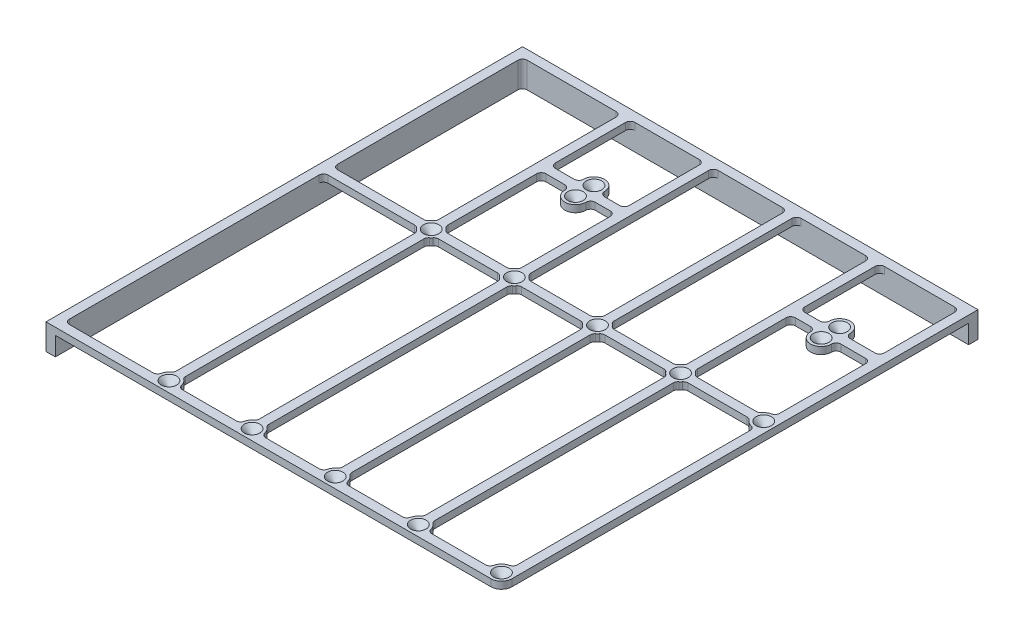
from build123d import *

# Parameters (mm, degrees)
SKETCH1_R           = 0.5
BOSS_EXTRUDE1_DEPTH = 3
BOSS_EXTRUDE2_DEPTH = 8
FILLET1_R           = 2
CHAMFER1_SIZE       = 2.8


with BuildPart() as part:
    # Sketch1 → Boss-Extrude1 (new body)
    with BuildSketch(Plane(origin=(0, 0, 0), x_dir=(1, 0, 0), z_dir=(0, 1, 0))):
        with BuildLine():
            Line((0, -199.5), (-4, -199.5))
            Line((-4, -199.5), (-4, 4))
            Line((-4, 4), (190.5, 4))
            Line((190.5, 4), (190.5, 0))
            Line((190.5, 0), (190.5, -195))
            ThreePointArc((190.5, -195), (189.181980515, -198.181980515), (186, -199.5))
            Line((186, -199.5), (0, -199.5))
        make_face()
        with Locations((44, -195)):
            Circle(SKETCH1_R, mode=Mode.SUBTRACT)
        with Locations((44, -83)):
            Circle(SKETCH1_R, mode=Mode.SUBTRACT)
        with Locations((79.5, -195)):
            Circle(SKETCH1_R, mode=Mode.SUBTRACT)
        with Locations((79.5, -83)):
            Circle(SKETCH1_R, mode=Mode.SUBTRACT)
        with Locations((115, -195)):
            Circle(SKETCH1_R, mode=Mode.SUBTRACT)
        with Locations((115, -83)):
            Circle(SKETCH1_R, mode=Mode.SUBTRACT)
        with Locations((150.5, -195)):
            Circle(SKETCH1_R, mode=Mode.SUBTRACT)
        with Locations((150.5, -83)):
            Circle(SKETCH1_R, mode=Mode.SUBTRACT)
        with Locations((186, -195)):
            Circle(SKETCH1_R, mode=Mode.SUBTRACT)
        with Locations((186, -83)):
            Circle(SKETCH1_R, mode=Mode.SUBTRACT)
        with Locations((62.545, -32.045)):
            Circle(SKETCH1_R, mode=Mode.SUBTRACT)
        with Locations((62.545, -39.955)):
            Circle(SKETCH1_R, mode=Mode.SUBTRACT)
        with Locations((167.455, -32.045)):
            Circle(SKETCH1_R, mode=Mode.SUBTRACT)
        with Locations((167.455, -39.955)):
            Circle(SKETCH1_R, mode=Mode.SUBTRACT)
        with BuildLine():
            Line((186.5, -190.527864045), (186.5, -87.472135955))
            ThreePointArc((186.5, -87.472135955), (183.844754811, -86.950306086), (181.968871126, -85))
            Line((181.968871126, -85), (154.531128874, -85))
            ThreePointArc((154.531128874, -85), (153.681980515, -86.181980515), (152.5, -87.031128874))
            Line((152.5, -87.031128874), (152.5, -190.968871126))
            ThreePointArc((152.5, -190.968871126), (154.450306086, -192.844754811), (154.972135955, -195.5))
            Line((154.972135955, -195.5), (181.527864045, -195.5))
            ThreePointArc((181.527864045, -195.5), (182.818019485, -191.818019485), (186.5, -190.527864045))
        make_face(mode=Mode.SUBTRACT)
        with BuildLine():
            Line((148.5, -190.968871126), (148.5, -87.031128874))
            ThreePointArc((148.5, -87.031128874), (147.318019485, -86.181980515), (146.468871126, -85))
            Line((146.468871126, -85), (119.031128874, -85))
            ThreePointArc((119.031128874, -85), (118.181980515, -86.181980515), (117, -87.031128874))
            Line((117, -87.031128874), (117, -190.968871126))
            ThreePointArc((117, -190.968871126), (118.950306086, -192.844754811), (119.472135955, -195.5))
            Line((119.472135955, -195.5), (146.027864045, -195.5))
            ThreePointArc((146.027864045, -195.5), (146.549693914, -192.844754811), (148.5, -190.968871126))
        make_face(mode=Mode.SUBTRACT)
        with BuildLine():
            Line((83.531128874, -85), (110.968871126, -85))
            ThreePointArc((110.968871126, -85), (111.818019485, -86.181980515), (113, -87.031128874))
            Line((113, -87.031128874), (113, -190.968871126))
            ThreePointArc((113, -190.968871126), (111.049693914, -192.844754811), (110.527864045, -195.5))
            Line((110.527864045, -195.5), (83.972135955, -195.5))
            ThreePointArc((83.972135955, -195.5), (83.450306086, -192.844754811), (81.5, -190.968871126))
            Line((81.5, -190.968871126), (81.5, -87.031128874))
            ThreePointArc((81.5, -87.031128874), (82.681980515, -86.181980515), (83.531128874, -85))
        make_face(mode=Mode.SUBTRACT)
        with BuildLine():
            Line((48.031128874, -85), (75.468871126, -85))
            ThreePointArc((75.468871126, -85), (76.318019485, -86.181980515), (77.5, -87.031128874))
            Line((77.5, -87.031128874), (77.5, -190.968871126))
            ThreePointArc((77.5, -190.968871126), (75.549693914, -192.844754811), (75.027864045, -195.5))
            Line((75.027864045, -195.5), (48.472135955, -195.5))
            ThreePointArc((48.472135955, -195.5), (47.950306086, -192.844754811), (46, -190.968871126))
            Line((46, -190.968871126), (46, -87.031128874))
            ThreePointArc((46, -87.031128874), (47.181980515, -86.181980515), (48.031128874, -85))
        make_face(mode=Mode.SUBTRACT)
        with BuildLine():
            Line((39.527864045, -195.5), (0, -195.5))
            Line((0, -195.5), (0, -85))
            Line((0, -85), (39.968871126, -85))
            ThreePointArc((39.968871126, -85), (40.818019485, -86.181980515), (42, -87.031128874))
            Line((42, -87.031128874), (42, -190.968871126))
            ThreePointArc((42, -190.968871126), (40.049693914, -192.844754811), (39.527864045, -195.5))
        make_face(mode=Mode.SUBTRACT)
        with BuildLine():
            Line((58.045, -32.045), (58.045, -34))
            Line((58.045, -34), (46, -34))
            Line((46, -34), (46, 0))
            Line((46, 0), (77.5, 0))
            Line((77.5, 0), (77.5, -34))
            Line((77.5, -34), (67.045, -34))
            Line((67.045, -34), (67.045, -32.045))
            ThreePointArc((67.045, -32.045), (62.545, -27.545), (58.045, -32.045))
        make_face(mode=Mode.SUBTRACT)
        with BuildLine():
            Line((39.968871126, -81), (0, -81))
            Line((0, -81), (0, 0))
            Line((0, 0), (42, 0))
            Line((42, 0), (42, -78.968871126))
            ThreePointArc((42, -78.968871126), (40.818019485, -79.818019485), (39.968871126, -81))
        make_face(mode=Mode.SUBTRACT)
        with BuildLine():
            Line((48.031128874, -81), (75.468871126, -81))
            ThreePointArc((75.468871126, -81), (76.318019485, -79.818019485), (77.5, -78.968871126))
            Line((77.5, -78.968871126), (77.5, -38))
            Line((77.5, -38), (67.045, -38))
            Line((67.045, -38), (67.045, -39.955))
            ThreePointArc((67.045, -39.955), (62.545, -44.455), (58.045, -39.955))
            Line((58.045, -39.955), (58.045, -38))
            Line((58.045, -38), (46, -38))
            Line((46, -38), (46, -78.968871126))
            ThreePointArc((46, -78.968871126), (47.181980515, -79.818019485), (48.031128874, -81))
        make_face(mode=Mode.SUBTRACT)
        with BuildLine():
            Line((83.531128874, -81), (110.968871126, -81))
            ThreePointArc((110.968871126, -81), (111.818019485, -79.818019485), (113, -78.968871126))
            Line((113, -78.968871126), (113, 0))
            Line((113, 0), (81.5, 0))
            Line((81.5, 0), (81.5, -78.968871126))
            ThreePointArc((81.5, -78.968871126), (82.681980515, -79.818019485), (83.531128874, -81))
        make_face(mode=Mode.SUBTRACT)
        with BuildLine():
            Line((119.031128874, -81), (146.468871126, -81))
            ThreePointArc((146.468871126, -81), (147.318019485, -79.818019485), (148.5, -78.968871126))
            Line((148.5, -78.968871126), (148.5, 0))
            Line((148.5, 0), (117, 0))
            Line((117, 0), (117, -78.968871126))
            ThreePointArc((117, -78.968871126), (118.181980515, -79.818019485), (119.031128874, -81))
        make_face(mode=Mode.SUBTRACT)
        with BuildLine():
            Line((154.531128874, -81), (181.968871126, -81))
            ThreePointArc((181.968871126, -81), (183.844754811, -79.049693914), (186.5, -78.527864045))
            Line((186.5, -78.527864045), (186.5, -38))
            Line((186.5, -38), (171.955, -38))
            Line((171.955, -38), (171.955, -39.955))
            ThreePointArc((171.955, -39.955), (167.455, -44.455), (162.955, -39.955))
            Line((162.955, -39.955), (162.955, -38))
            Line((162.955, -38), (152.5, -38))
            Line((152.5, -38), (152.5, -78.968871126))
            ThreePointArc((152.5, -78.968871126), (153.681980515, -79.818019485), (154.531128874, -81))
        make_face(mode=Mode.SUBTRACT)
        with BuildLine():
            Line((186.5, 0), (152.5, 0))
            Line((152.5, 0), (152.5, -34))
            Line((152.5, -34), (162.955, -34))
            Line((162.955, -34), (162.955, -32.045))
            ThreePointArc((162.955, -32.045), (167.455, -27.545), (171.955, -32.045))
            Line((171.955, -32.045), (171.955, -34))
            Line((171.955, -34), (186.5, -34))
            Line((186.5, -34), (186.5, 0))
        make_face(mode=Mode.SUBTRACT)
    extrude(amount=BOSS_EXTRUDE1_DEPTH)

    # Sketch2 → Boss-Extrude2 (add)
    with BuildSketch(Plane.XZ):
        Polygon((190.5, 0), (190.5, -4), (-4, -4), (-4, 199.5), (0, 199.5), (0, 0), align=None)
    extrude(amount=BOSS_EXTRUDE2_DEPTH)

    # Fillet1
    fillet1_edges = [part.edges().sort_by_distance(p)[0] for p in [
        (152.5, 1.5, 190.968871126),
        (154.972135955, 1.5, 195.5),
        (119.472135955, 1.5, 195.5),
        (117, 1.5, 190.968871126),
        (81.5, 1.5, 190.968871126),
        (83.972135955, 1.5, 195.5),
        (46, 1.5, 190.968871126),
        (48.472135955, 1.5, 195.5),
        (81.5, 1.5, 87.031128874),
        (81.5, 1.5, 0),
        (186.5, 1.5, 190.527864045),
        (181.527864045, 1.5, 195.5),
        (148.5, 1.5, 190.968871126),
        (146.027864045, 1.5, 195.5),
        (113, 1.5, 190.968871126),
        (110.527864045, 1.5, 195.5),
        (77.5, 1.5, 190.968871126),
        (75.027864045, 1.5, 195.5),
        (42, 1.5, 190.968871126),
        (39.527864045, 1.5, 195.5),
        (0, 1.5, 195.5),
        (0, -2.5, 0),
        (0, 1.5, 81),
        (0, 1.5, 85),
        (110.968871126, 1.5, 85),
        (113, 1.5, 87.031128874),
        (113, 1.5, 78.968871126),
        (110.968871126, 1.5, 81),
        (148.5, 1.5, 78.968871126),
        (146.468871126, 1.5, 81),
        (117, 1.5, 78.968871126),
        (119.031128874, 1.5, 81),
        (119.031128874, 1.5, 85),
        (117, 1.5, 87.031128874),
        (146.468871126, 1.5, 85),
        (148.5, 1.5, 87.031128874),
        (186.5, 1.5, 87.472135955),
        (181.968871126, 1.5, 85),
        (186.5, 1.5, 78.527864045),
        (181.968871126, 1.5, 81),
        (152.5, 1.5, 78.968871126),
        (154.531128874, 1.5, 81),
        (154.531128874, 1.5, 85),
        (152.5, 1.5, 87.031128874),
        (171.955, 1.5, 38),
        (152.5, 1.5, 38),
        (162.955, 1.5, 38),
        (186.5, 1.5, 38),
        (186.5, 1.5, 34),
        (162.955, 1.5, 34),
        (152.5, 1.5, 34),
        (171.955, 1.5, 34),
        (186.5, 1.5, 0),
        (148.5, 1.5, 0),
        (152.5, 1.5, 0),
        (117, 1.5, 0),
        (113, 1.5, 0),
        (42, 1.5, 0),
        (77.5, 1.5, 0),
        (46, 1.5, 0),
        (46, 1.5, 34),
        (77.5, 1.5, 34),
        (77.5, 1.5, 38),
        (58.045, 1.5, 34),
        (67.045, 1.5, 34),
        (67.045, 1.5, 38),
        (58.045, 1.5, 38),
        (46, 1.5, 38),
        (81.5, 1.5, 78.968871126),
        (83.531128874, 1.5, 81),
        (83.531128874, 1.5, 85),
        (77.5, 1.5, 87.031128874),
        (75.468871126, 1.5, 85),
        (77.5, 1.5, 78.968871126),
        (75.468871126, 1.5, 81),
        (42, 1.5, 78.968871126),
        (39.968871126, 1.5, 81),
        (46, 1.5, 78.968871126),
        (48.031128874, 1.5, 81),
        (48.031128874, 1.5, 85),
        (46, 1.5, 87.031128874),
        (42, 1.5, 87.031128874),
        (39.968871126, 1.5, 85),
    ]]
    fillet(fillet1_edges, radius=FILLET1_R)

    # Chamfer1
    chamfer1_edges = [part.edges().sort_by_distance(p)[0] for p in [
        (62.045, 3, 39.955),
        (62.045, 3, 32.045),
        (166.955, 3, 32.045),
        (166.955, 3, 39.955),
        (43.5, 3, 83),
        (43.5, 3, 195),
        (79, 3, 83),
        (79, 3, 195),
        (114.5, 3, 83),
        (114.5, 3, 195),
        (150, 3, 83),
        (150, 3, 195),
        (185.5, 3, 83),
        (185.5, 3, 195),
    ]]
    chamfer(chamfer1_edges, length=CHAMFER1_SIZE)


solid = part.part
